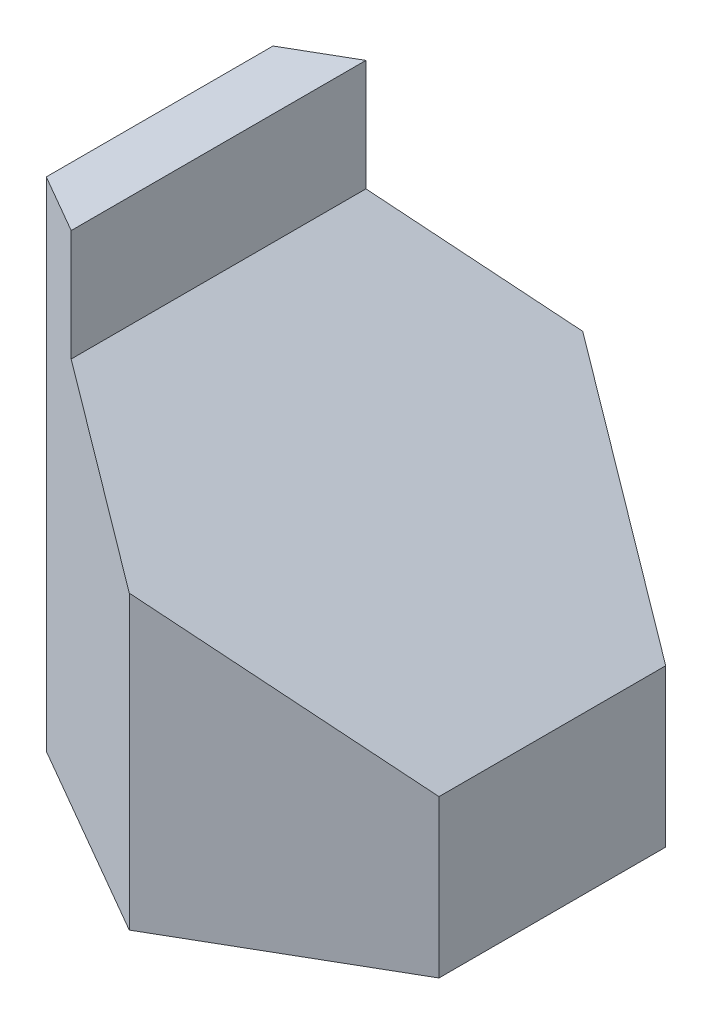
from build123d import *

# Parameters (mm, degrees)
EXTRUDE_2_DEPTH     = 76
SKETCH_5_W          = 69.282032302
SKETCH_5_H          = 17
CUT_EXTRUDE_2_DEPTH = 51
SKETCH_7_W          = 79.816599869
SKETCH_7_H          = 73.41094556
CUT_EXTRUDE_3_DEPTH = 51


with BuildPart() as part:
    # 草图1 → 凸台-拉伸2 (new body)
    with BuildSketch(Plane(origin=(0, 0, 0), x_dir=(1, 0, 0), z_dir=(0, 1, 0))):
        Polygon((0, 34.641016151), (-30, 17.320508076), (-30, -17.320508076), (0, -34.641016151), (30, -17.320508076), (30, 17.320508076), align=None)
    extrude(amount=EXTRUDE_2_DEPTH)

    # 草图5 → 切除-拉伸2 (cut)
    with BuildSketch(Plane(origin=(30, 0, 0), x_dir=(0, 0, -1), z_dir=(1, 0, 0))):
        with Locations((0, 67.5)):
            Rectangle(SKETCH_5_W, SKETCH_5_H)
    extrude(amount=-CUT_EXTRUDE_2_DEPTH, mode=Mode.SUBTRACT)

    # 草图7 → 切除-拉伸3 (cut)
    with BuildSketch(Plane(origin=(20.8024046, 30.312075274, 0), x_dir=(-0.824513353, 0.565842497, 0), z_dir=(-0.565842497, -0.824513353, 0))):
        with Locations((10.791187789, -0.103687776)):
            Rectangle(SKETCH_7_W, SKETCH_7_H)
    extrude(amount=-CUT_EXTRUDE_3_DEPTH, mode=Mode.SUBTRACT)


solid = part.part
